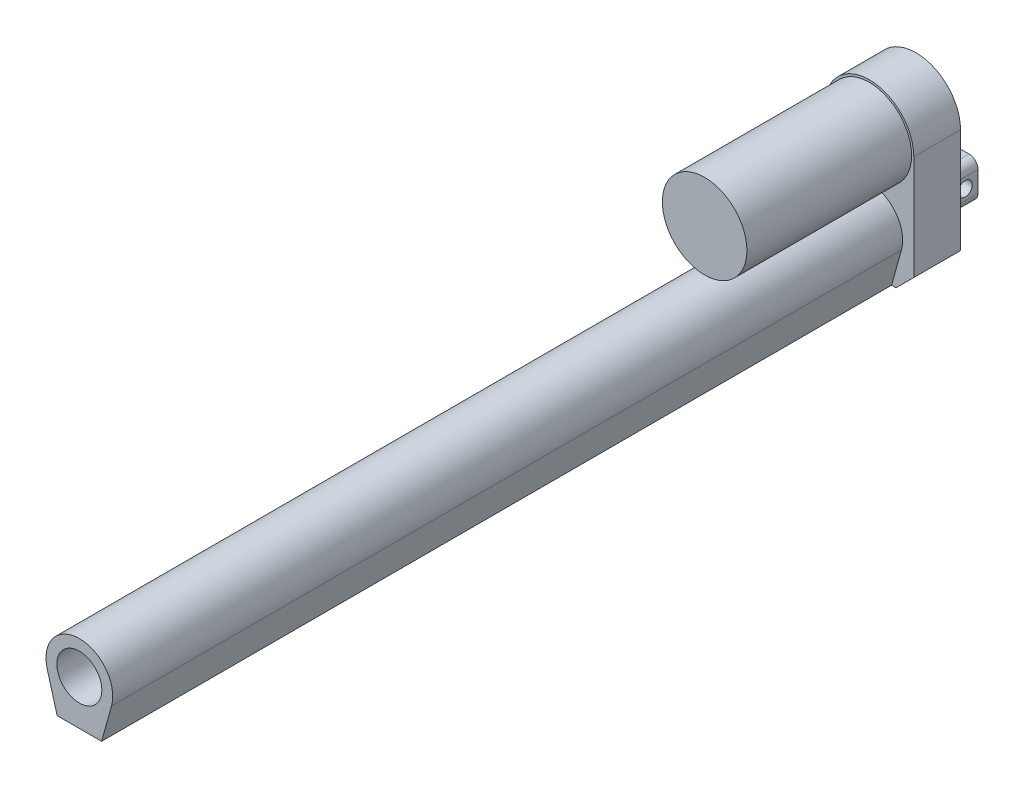
from build123d import *

# Parameters (mm, degrees)
BOSS_EXTRUDE1_DEPTH     = 21
SKETCH2_R               = 19
BOSS_EXTRUDE2_DEPTH     = 74
BOSS_EXTRUDE3_DEPTH     = 355
SKETCH4_W               = 17.3
SKETCH4_H               = 17.3
BOSS_EXTRUDE4_DEPTH     = 19.2
FILLET1_R               = 4
SKETCH5_R               = 10.1
CUT_EXTRUDE1_DEPTH      = 300
SKETCH6_R               = 3.175
CUT_EXTRUDE2_DEPTH      = 21
CUT_EXTRUDE2_DEPTH_BACK = 21


with BuildPart() as part:
    # Sketch1 → Boss-Extrude1 (new body)
    with BuildSketch(Plane.XY):
        with BuildLine():
            Line((-12, -37.5), (12, -37.5))
            Line((12, -37.5), (20, -29.5))
            Line((20, -29.5), (20, 17.5))
            ThreePointArc((20, 17.5), (0, 37.5), (-20, 17.5))
            Line((-20, 17.5), (-20, -29.5))
            Line((-20, -29.5), (-12, -37.5))
        make_face()
    extrude(amount=BOSS_EXTRUDE1_DEPTH)

    # Sketch2 → Boss-Extrude2 (add)
    with BuildSketch(Plane.XY.offset(21)):
        with Locations((0, 17.5)):
            Circle(SKETCH2_R)
    extrude(amount=BOSS_EXTRUDE2_DEPTH)

    # Sketch3 → Boss-Extrude3 (add)
    with BuildSketch(Plane.XY.offset(21)):
        with BuildLine():
            Line((14.449874371, -21.525062814), (10, -37.5))
            Line((10, -37.5), (-10, -37.5))
            Line((-10, -37.5), (-14.449874371, -21.525062814))
            ThreePointArc((-14.449874371, -21.525062814), (0, -2.5), (14.449874371, -21.525062814))
        make_face()
    extrude(amount=BOSS_EXTRUDE3_DEPTH)

    # Sketch4 → Boss-Extrude4 (add)
    with BuildSketch(Plane(origin=(0, 0, 0), x_dir=(-1, 0, 0), z_dir=(0, 0, -1))):
        with Locations((0, -17.85)):
            Rectangle(SKETCH4_W, SKETCH4_H)
    extrude(amount=BOSS_EXTRUDE4_DEPTH)

    # Fillet1
    fillet1_edges = [part.edges().sort_by_distance(p)[0] for p in [
        (-8.65, -26.5, -9.6),
        (-8.65, -9.2, -9.6),
        (8.65, -9.2, -9.6),
        (8.65, -26.5, -9.6),
    ]]
    fillet(fillet1_edges, radius=FILLET1_R)

    # Sketch5 → Cut-Extrude1 (cut)
    with BuildSketch(Plane.XY.offset(376)):
        with Locations((0, -17.5)):
            Circle(SKETCH5_R)
    extrude(amount=-CUT_EXTRUDE1_DEPTH, mode=Mode.SUBTRACT)

    # Sketch6 → Cut-Extrude2 (cut, two sides)
    with BuildSketch(Plane(origin=(0, 0, 0), x_dir=(0, 0, -1), z_dir=(1, 0, 0))) as cut_extrude2_sk:
        with Locations((13.45, -17.85)):
            Circle(SKETCH6_R)
    extrude(amount=CUT_EXTRUDE2_DEPTH, mode=Mode.SUBTRACT)
    extrude(cut_extrude2_sk.sketch, amount=-CUT_EXTRUDE2_DEPTH_BACK, mode=Mode.SUBTRACT)


solid = part.part
